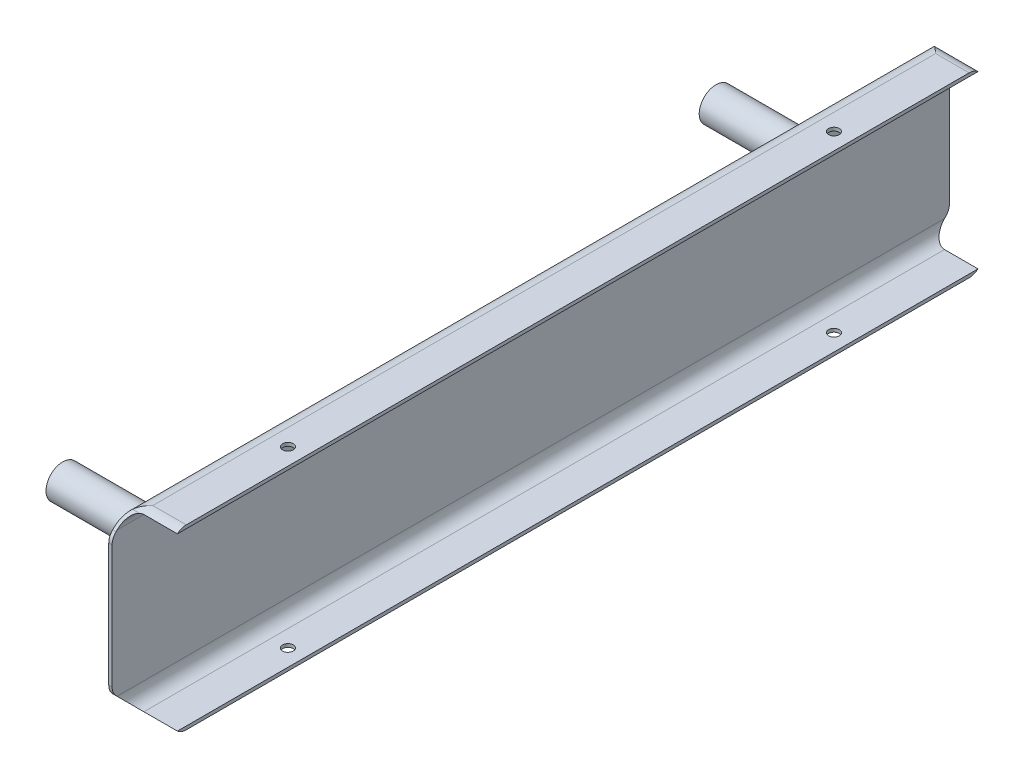
from build123d import *

# Parameters (mm, degrees)
BOSS_EXTRU_1_DEPTH      = 250
ENL_V_MAT_EXTRU_1_DEPTH = 16
D_GAGEMENT_M31_D        = 3.2
ESQUISSE6_R             = 5
BOSS_EXTRU_2_DEPTH      = 41.23


with BuildPart() as part:
    # Esquisse1 → Boss.-Extru.1 (new body)
    with BuildSketch(Plane.XY):
        with BuildLine():
            Line((0, 5), (0, 48))
            ThreePointArc((0, 48), (1.464466094, 51.535533906), (5, 53))
            Line((5, 53), (15, 53))
            Line((15, 53), (15, 52))
            Line((15, 52), (5, 52))
            ThreePointArc((5, 52), (2.171572875, 50.828427125), (1, 48))
            Line((1, 48), (1, 5))
            ThreePointArc((1, 5), (2.171572875, 2.171572875), (5, 1))
            Line((5, 1), (15, 1))
            Line((15, 1), (15, 0))
            Line((15, 0), (5, 0))
            ThreePointArc((5, 0), (1.464466094, 1.464466094), (0, 5))
        make_face()
    extrude(amount=BOSS_EXTRU_1_DEPTH)

    # Esquisse5 → Enlèv. mat.-Extru.1 (cut, through all)
    with BuildSketch(Plane.ZY):
        with BuildLine():
            Line((0, 8.142135624), (0, -1))
            Line((0, -1), (21.071067812, -1))
            Line((21.071067812, -1), (21.071067812, 0))
            Line((21.071067812, 0), (8.142135624, 0))
            ThreePointArc((8.142135624, 0), (6.611401894, 0.30448187), (5.313708499, 1.171572875))
            Line((5.313708499, 1.171572875), (1.171572875, 5.313708499))
            ThreePointArc((1.171572875, 5.313708499), (0.30448187, 6.611401894), (0, 8.142135624))
        make_face()
        with BuildLine():
            Line((8.142135624, 53), (21.071067812, 53))
            Line((21.071067812, 53), (21.071067812, 54))
            Line((21.071067812, 54), (0, 54))
            Line((0, 54), (0, 44.857864376))
            ThreePointArc((0, 44.857864376), (0.30448187, 46.388598106), (1.171572875, 47.686291501))
            Line((1.171572875, 47.686291501), (5.313708499, 51.828427125))
            ThreePointArc((5.313708499, 51.828427125), (6.611401894, 52.69551813), (8.142135624, 53))
        make_face()
    enl_v_mat_extru_1 = extrude(amount=-ENL_V_MAT_EXTRU_1_DEPTH, mode=Mode.SUBTRACT)

    # Symétrie1: Enlèv. mat.-Extru.1 across plane
    add(enl_v_mat_extru_1.mirror(Plane(origin=(0, 0, 125), x_dir=(1, 0, 0), z_dir=(0, 0, -1))), mode=Mode.SUBTRACT)

    # Dégagement M31 (through all)
    with Locations(Plane(origin=(0, 53, 0), x_dir=(1, 0, 0), z_dir=(0, 1, 0))):
        with Locations((10, -43.5), (10, -206.5)):
            Hole(D_GAGEMENT_M31_D / 2)

    # Esquisse6 → Boss.-Extru.2 (add)
    with BuildSketch(Plane.ZY):
        with Locations((27.5, 26.5)):
            Circle(ESQUISSE6_R)
        with Locations((222.5, 26.5)):
            Circle(ESQUISSE6_R)
    extrude(amount=BOSS_EXTRU_2_DEPTH)


solid = part.part
